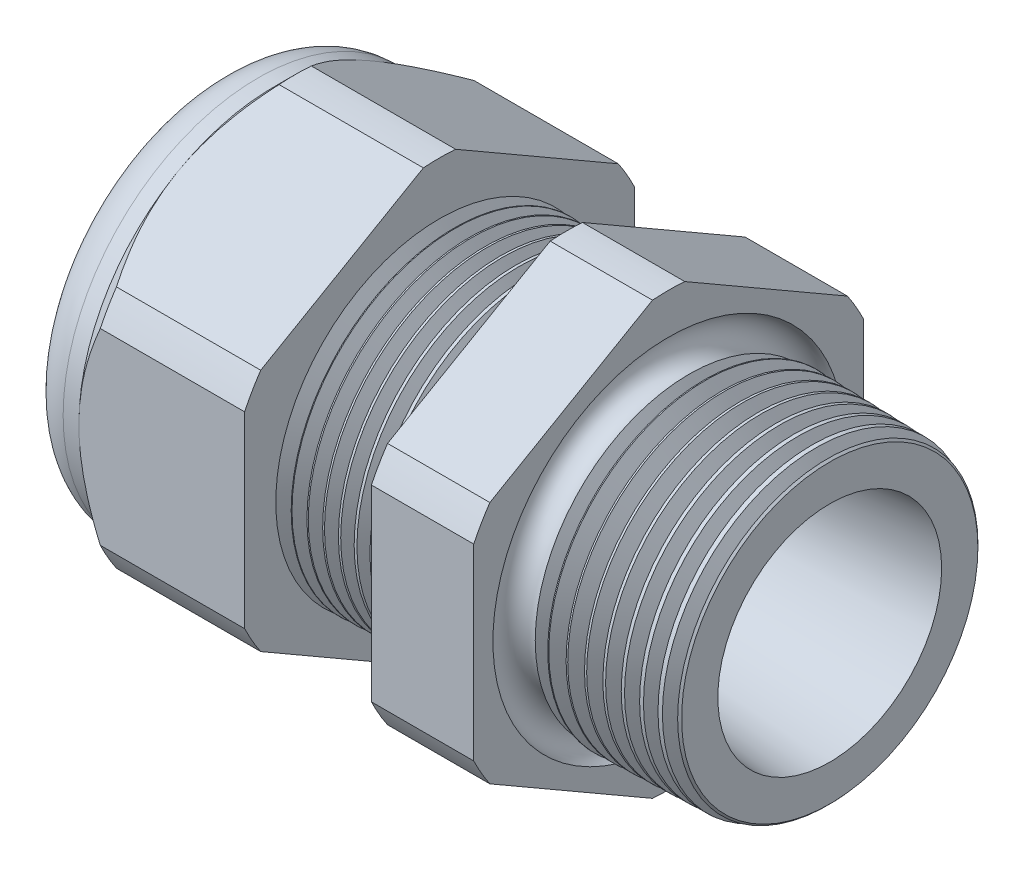
from build123d import *

# Parameters (mm, degrees)
SKETCH12_OUTSIDE_W = 52.432
SKETCH12_OUTSIDE_H = 52.432
CUT_EXTRUDE2_DEPTH = 28.172
FILLET4_R          = 2.032
SKETCH19_OUTSIDE_W = 33.316
SKETCH19_OUTSIDE_H = 35.412
SKETCH19_OUTSIDE_R = 9.525
CUT_EXTRUDE3_DEPTH = 1.999996
CUT_EXTRUDE3_DRAFT = -45
CHAMFER1_SIZE      = 0.260919487
CHAMFER1_SIZE2     = 0.254
SKETCH21_R         = 3.937
PLUG_DEPTH         = 3.81
SKETCH22_R         = 3.683
CUT_EXTRUDE4_DEPTH = 0.508
SKETCH27_R         = 0.889
PLUGHOLES_DEPTH    = 30.464
CIRPATTERN1_COUNT  = 2
LPATTERN1_COUNT    = 8
LPATTERN1_PITCH    = 0.762
LPATTERN2_COUNT    = 9
LPATTERN2_PITCH    = 0.889
SKETCH32_R         = 0.889


with BuildPart() as part:
    # Sketch10 → Revolve2 (revolve)
    with BuildSketch(Plane.XY, mode=Mode.PRIVATE) as revolve2_sk:
        Polygon((-29.972, 3.937), (-19.072, 3.937), (0, 5.469582104), (0, 7.501582104), (-7.874, 7.70777005), (-7.874, 19.05), (-12.874, 19.05), (-12.874, 7.838699658), (-19.072, 8.001), (-19.072, 19.05), (-27.172, 19.05), (-27.172, 9.525), (-29.972, 9.525), align=None)
    revolve(revolve2_sk.sketch.rotate(Axis((0, 0, 0), (-1, 0, 0)), 90), axis=Axis((0, 0, 0), (-1, 0, 0)))  # turned: the seam where the file's is

    # Sketch12 outside → Cut-Extrude2 (cut, through all)
    with BuildSketch(Plane.ZY.offset(27.172)):
        Rectangle(SKETCH12_OUTSIDE_W, SKETCH12_OUTSIDE_H)
        with BuildLine():
            Line((-0.788451287, 10.543310065), (-8.736548713, 5.954473877))
            ThreePointArc((-8.736548713, 5.954473877), (-9.156270088, 5.286375), (-9.525, 4.588836188))
            Line((-9.525, 4.588836188), (-9.525, -4.588836188))
            ThreePointArc((-9.525, -4.588836188), (-9.156270088, -5.286375), (-8.736548713, -5.954473877))
            Line((-8.736548713, -5.954473877), (-0.788451287, -10.543310065))
            ThreePointArc((-0.788451287, -10.543310065), (0, -10.57275), (0.788451287, -10.543310065))
            Line((0.788451287, -10.543310065), (8.736548713, -5.954473877))
            ThreePointArc((8.736548713, -5.954473877), (9.156270088, -5.286375), (9.525, -4.588836188))
            Line((9.525, -4.588836188), (9.525, 4.588836188))
            ThreePointArc((9.525, 4.588836188), (9.156270088, 5.286375), (8.736548713, 5.954473877))
            Line((8.736548713, 5.954473877), (0.788451287, 10.543310065))
            ThreePointArc((0.788451287, 10.543310065), (0, 10.57275), (-0.788451287, 10.543310065))
        make_face(mode=Mode.SUBTRACT)
    extrude(amount=-CUT_EXTRUDE2_DEPTH, mode=Mode.SUBTRACT)

    # Fillet4
    fillet4_edges = [part.edges().sort_by_distance(p)[0] for p in [
        (-29.972, 0, 9.525),
    ]]
    fillet(fillet4_edges, radius=FILLET4_R)


with BuildPart() as cut_extrude3_tool:
    # Sketch19 outside → Cut-Extrude3 (with draft: the straight prism first)
    with BuildSketch(Plane.ZY.offset(27.172)):
        Rectangle(SKETCH19_OUTSIDE_W, SKETCH19_OUTSIDE_H)
        Circle(SKETCH19_OUTSIDE_R, mode=Mode.SUBTRACT)
    extrude(amount=-CUT_EXTRUDE3_DEPTH)
    # Cut-Extrude3: the draft: its side faces are tilted about the plane it starts from
    cut_extrude3_sides = [cut_extrude3_tool.faces().sort_by_distance(p)[0] for p in [
        (-26.172002, -17.706, 0),
        (-26.172002, 0, 16.658),
        (-26.172002, 17.706, 0),
        (-26.172002, 0, -16.658),
        (-26.172002, 0, -9.525),
    ]]
    draft(cut_extrude3_sides, Plane.ZY.offset(27.172), CUT_EXTRUDE3_DRAFT)


with BuildPart() as part_1:
    add(part.part)

    # Cut-Extrude3: cut by cut_extrude3_tool
    add(cut_extrude3_tool.part, mode=Mode.SUBTRACT)

    # Chamfer1
    chamfer1_edges = [part_1.edges().sort_by_distance(p)[0] for p in [
        (0, 0, 7.501582104),
    ]]
    chamfer1_side = [part_1.faces().sort_by_distance(p)[0] for p in [
        (0, 0, 5.681758887),
    ]]
    chamfer(chamfer1_edges, length=CHAMFER1_SIZE, length2=CHAMFER1_SIZE2, reference=chamfer1_side[0])

    # Sketch29 → Cut-Revolve1 (revolve, cut)
    with BuildSketch(Plane.XY, mode=Mode.PRIVATE) as cut_revolve1_sk:
        Polygon((-19.072, 8.001), (-18.339016419, 7.981806149), (-18.722130572, 7.356620673), align=None)
    cut_revolve1 = revolve(cut_revolve1_sk.sketch.rotate(Axis((0, 0, 0), (-1, 0, 0)), 90), axis=Axis((0, 0, 0), (-1, 0, 0)), mode=Mode.SUBTRACT)  # turned: the seam where the file's is

    # LPattern1: Cut-Revolve1 ×8
    with Locations(*[(i * LPATTERN1_PITCH, 0, 0) for i in range(1, LPATTERN1_COUNT)]):
        add(cut_revolve1, mode=Mode.SUBTRACT)

    # Sketch30 → Cut-Revolve2 (revolve, cut)
    with BuildSketch(Plane.XY, mode=Mode.PRIVATE) as cut_revolve2_sk:
        Polygon((-7.874, 7.70777005), (-6.994419703, 7.68473743), (-7.454156686, 6.934514858), align=None)
    cut_revolve2 = revolve(cut_revolve2_sk.sketch.rotate(Axis((0, 0, 0), (-1, 0, 0)), 270), axis=Axis((0, 0, 0), (-1, 0, 0)), mode=Mode.SUBTRACT)  # turned: the seam where the file's is

    # LPattern2: Cut-Revolve2 ×9
    with Locations(*[(i * LPATTERN2_PITCH, 0, 0) for i in range(1, LPATTERN2_COUNT)]):
        add(cut_revolve2, mode=Mode.SUBTRACT)

    # Sketch32 → Cut-Revolve3 (revolve, cut)
    with BuildSketch(Plane.XY, mode=Mode.PRIVATE) as cut_revolve3_sk:
        with Locations((-7.747, 7.70777005)):
            Circle(SKETCH32_R)
    revolve(cut_revolve3_sk.sketch.rotate(Axis((0, 0, 0), (-1, 0, 0)), 270), axis=Axis((0, 0, 0), (-1, 0, 0)), mode=Mode.SUBTRACT)  # turned: the seam where the file's is


with BuildPart() as body_2:
    # Sketch21 → plug (new body)
    with BuildSketch(Plane.ZY.offset(29.972)):
        Circle(SKETCH21_R)
    extrude(amount=-PLUG_DEPTH)

    # Sketch22 → Cut-Extrude4 (cut)
    with BuildSketch(Plane.ZY.offset(29.972)):
        Circle(SKETCH22_R)
    extrude(amount=-CUT_EXTRUDE4_DEPTH, mode=Mode.SUBTRACT)

    # Sketch27 → plugholes (cut, through all)
    with BuildSketch(Plane.ZY.offset(29.464)):
        with Locations((-2.790444, 0)):
            Circle(SKETCH27_R)
    plugholes = extrude(amount=-PLUGHOLES_DEPTH, mode=Mode.SUBTRACT)

    # CirPattern1: plugholes ×2 about axis
    cirpattern1_axis = Axis((0, 0, 0), (1, 0, 0))
    for i in range(1, CIRPATTERN1_COUNT):
        add(plugholes.rotate(cirpattern1_axis, i * 360 / CIRPATTERN1_COUNT), mode=Mode.SUBTRACT)


solid = Compound([part_1.part, body_2.part])
